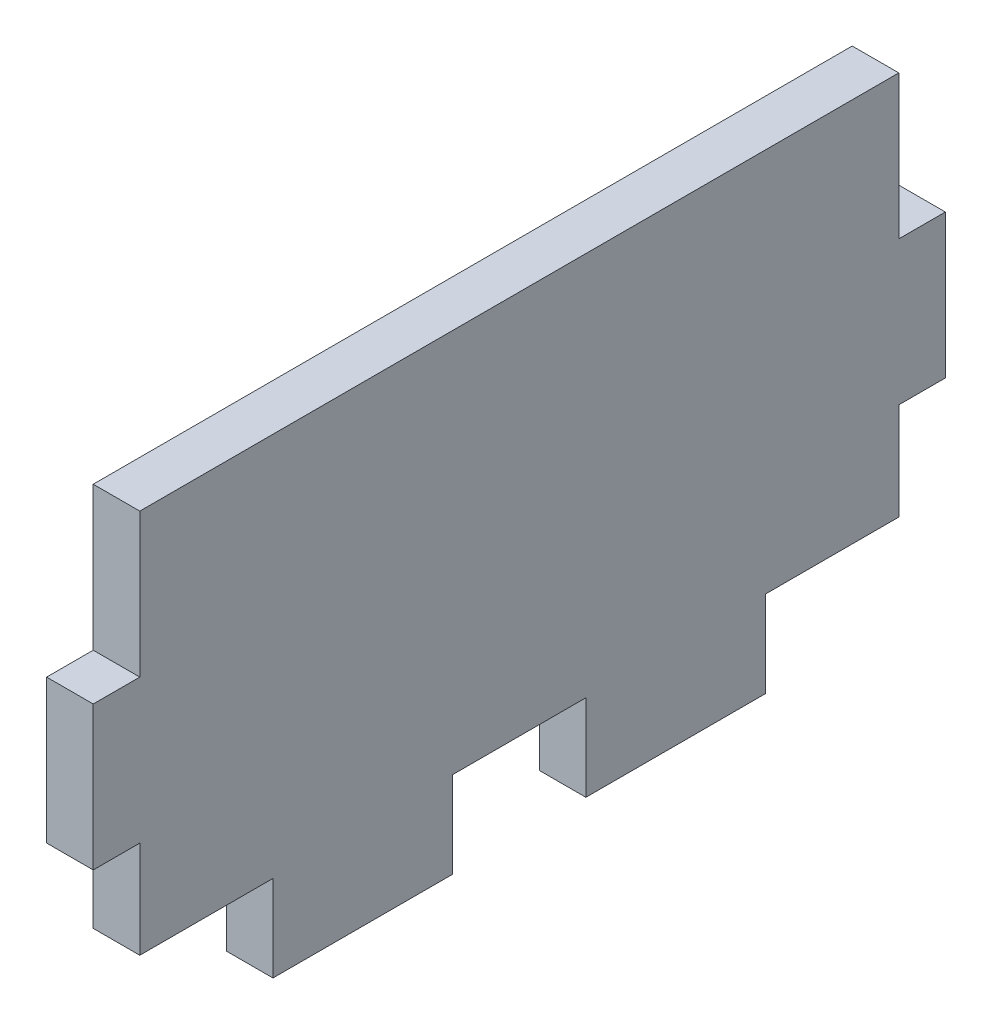
from build123d import *

# Parameters (mm, degrees)
BOSS_EXTRUDE2_DEPTH = 2.7


with BuildPart() as part:
    # Sketch1 → Boss-Extrude2 (new body)
    with BuildSketch(Plane(origin=(0, 0, 0), x_dir=(0, 0, -1), z_dir=(1, 0, 0))):
        Polygon((-24.7, -4.166666667), (-24.7, 4.166666667), (-22, 4.166666667), (-22, 12.5), (22, 12.5), (22, 4.166666667), (24.7, 4.166666667), (24.7, -4.166666667), (22, -4.166666667), (22, -9.8), (14.28, -9.8), (14.28, -12.5), (14.28, -14.8), (3.86, -14.8), (3.86, -12.5), (3.86, -9.8), (-3.86, -9.8), (-3.86, -12.5), (-3.86, -14.8), (-14.28, -14.8), (-14.28, -12.5), (-14.28, -9.8), (-22, -9.8), (-22, -4.166666667), align=None)
    extrude(amount=BOSS_EXTRUDE2_DEPTH)


solid = part.part
